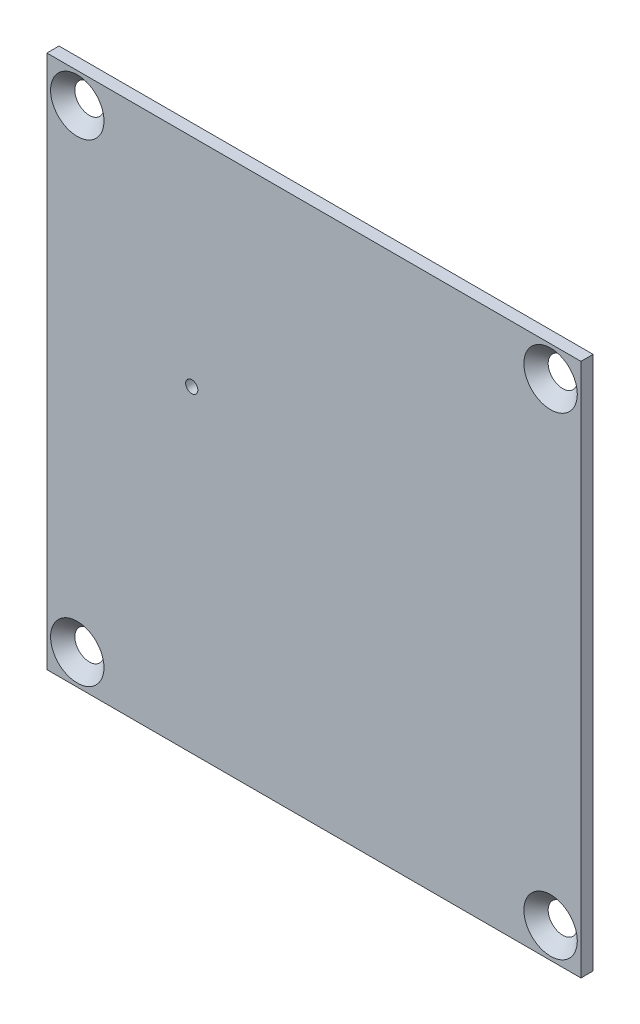
from build123d import *

# Parameters (mm, degrees)
ESQUISSE3_W                                 = 44
ESQUISSE3_H                                 = 44
BOSS_EXTRU_1_DEPTH                          = 1
SKETCH_HOLES_R                              = 0.5
CUT_EXTRUDE_HOLES_DEPTH                     = 2
FRAISAGE_POUR_VIS_T_TE_FRAIS_E_M21_AT_COUNT = 2
FRAISAGE_POUR_VIS_T_TE_FRAIS_E_M21_AT_PITCH = 39
FRAISAGE_POUR_VIS_T_TE_FRAIS_E_M21_2_COUNT  = 2
FRAISAGE_POUR_VIS_T_TE_FRAIS_E_M21_2_PITCH  = 55.154328933
FRAISAGE_POUR_VIS_T_TE_FRAIS_E_M21_3_COUNT  = 2
FRAISAGE_POUR_VIS_T_TE_FRAIS_E_M21_3_PITCH  = 39


with BuildPart() as part:
    # Esquisse3 → Boss.-Extru.1 (new body)
    with BuildSketch(Plane(origin=(0, 0, 0), x_dir=(0, 1, 0), z_dir=(0, 0, 1))):
        Rectangle(ESQUISSE3_W, ESQUISSE3_H)
    extrude(amount=BOSS_EXTRU_1_DEPTH)

    # Sketch_Holes → Cut_Extrude_Holes (cut, through all)
    with BuildSketch(Plane.XY.offset(1)):
        with Locations((-10.067654011, 4.160184375)):
            Circle(SKETCH_HOLES_R)
    extrude(amount=-CUT_EXTRUDE_HOLES_DEPTH, mode=Mode.SUBTRACT)

    # Esquisse5 → Fraisage pour vis à tête fraisée M21 (revolve, cut)
    with BuildSketch(Plane(origin=(19.5, -19.5, 1), x_dir=(0, -1, 0), z_dir=(1, 0, 0))):
        Polygon((0, 0), (0, 2), (1.2, 2), (1.2, 1), (2.2, 0), align=None)
    fraisage_pour_vis_t_te_frais_e_m21 = revolve(axis=Axis((19.5, -19.5, 7.35), (0, 0, -1)), mode=Mode.SUBTRACT)

    # Fraisage pour vis à tête fraisée M21 at: Fraisage pour vis à tête fraisée M21 ×2
    with Locations(*[(-i * FRAISAGE_POUR_VIS_T_TE_FRAIS_E_M21_AT_PITCH, 0, 0) for i in range(1, FRAISAGE_POUR_VIS_T_TE_FRAIS_E_M21_AT_COUNT)]):
        add(fraisage_pour_vis_t_te_frais_e_m21, mode=Mode.SUBTRACT)

    # Fraisage pour vis _ t_te frais_e M21 2: Fraisage pour vis à tête fraisée M21 ×2
    with Locations(*[Vector(-0.707106781, 0.707106781, 0) * (i * FRAISAGE_POUR_VIS_T_TE_FRAIS_E_M21_2_PITCH) for i in range(1, FRAISAGE_POUR_VIS_T_TE_FRAIS_E_M21_2_COUNT)]):
        add(fraisage_pour_vis_t_te_frais_e_m21, mode=Mode.SUBTRACT)

    # Fraisage pour vis _ t_te frais_e M21 3: Fraisage pour vis à tête fraisée M21 ×2
    with Locations(*[(0, i * FRAISAGE_POUR_VIS_T_TE_FRAIS_E_M21_3_PITCH, 0) for i in range(1, FRAISAGE_POUR_VIS_T_TE_FRAIS_E_M21_3_COUNT)]):
        add(fraisage_pour_vis_t_te_frais_e_m21, mode=Mode.SUBTRACT)


solid = part.part
